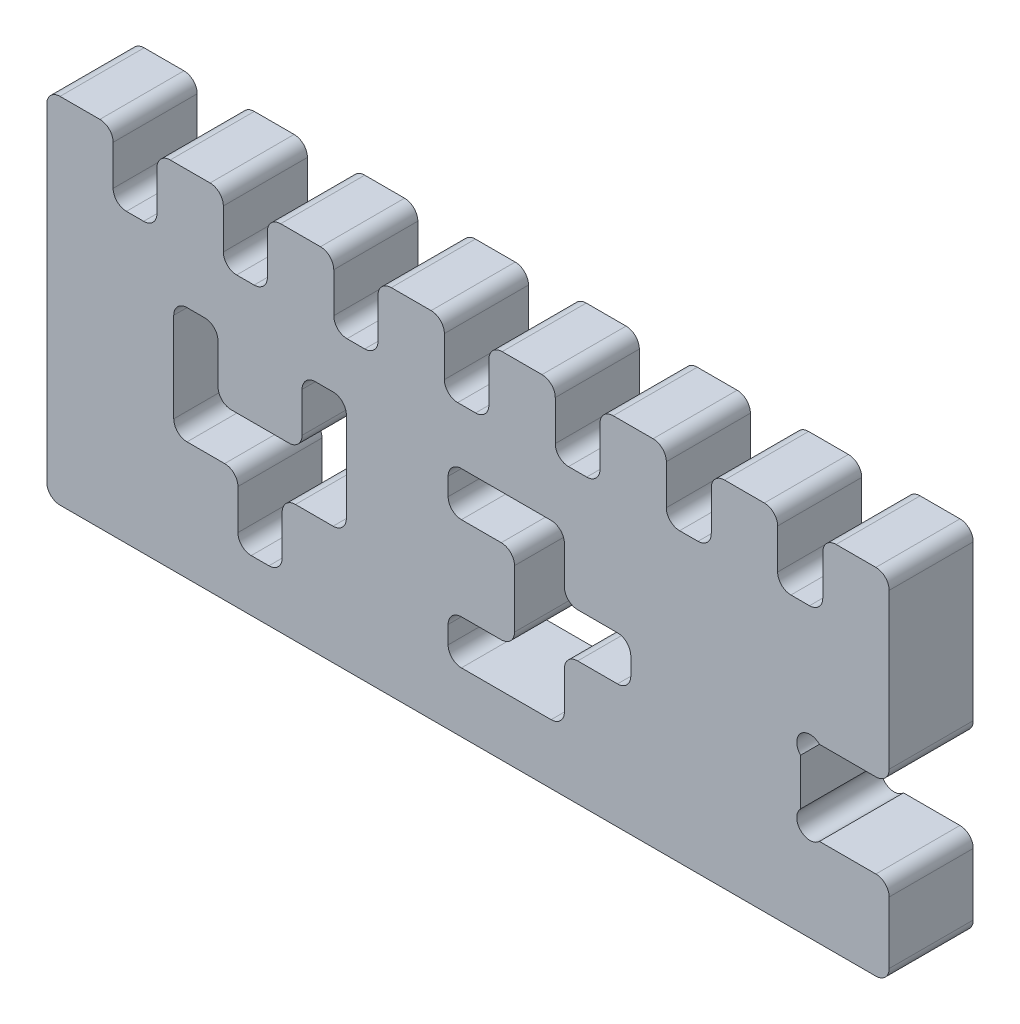
from build123d import *

# Parameters (mm, degrees)
BOSS_EXTRUDE1_DEPTH = 19


with BuildPart() as part:
    # Sketch1 → Boss-Extrude1 (new body)
    with BuildSketch(Plane.XY):
        with BuildLine():
            Line((18, 65), (21.9, 65))
            ThreePointArc((21.9, 65), (24.021320344, 65.878679656), (24.9, 68))
            Line((24.9, 68), (24.9, 77))
            ThreePointArc((24.9, 77), (25.778679656, 79.121320344), (27.9, 80))
            Line((27.9, 80), (36.9, 80))
            ThreePointArc((36.9, 80), (39.021320344, 79.121320344), (39.9, 77))
            Line((39.9, 77), (39.9, 68))
            ThreePointArc((39.9, 68), (40.778679656, 65.878679656), (42.9, 65))
            Line((42.9, 65), (46.85, 65))
            ThreePointArc((46.85, 65), (48.971320344, 65.878679656), (49.85, 68))
            Line((49.85, 68), (49.85, 77))
            ThreePointArc((49.85, 77), (50.728679656, 79.121320344), (52.85, 80))
            Line((52.85, 80), (61.85, 80))
            ThreePointArc((61.85, 80), (63.971320344, 79.121320344), (64.85, 77))
            Line((64.85, 77), (64.85, 68))
            ThreePointArc((64.85, 68), (65.728679656, 65.878679656), (67.85, 65))
            Line((67.85, 65), (71.85, 65))
            ThreePointArc((71.85, 65), (73.971320344, 65.878679656), (74.85, 68))
            Line((74.85, 68), (74.85, 77))
            ThreePointArc((74.85, 77), (75.728679656, 79.121320344), (77.85, 80))
            Line((77.85, 80), (86.85, 80))
            ThreePointArc((86.85, 80), (88.971320344, 79.121320344), (89.85, 77))
            Line((89.85, 77), (89.85, 68))
            ThreePointArc((89.85, 68), (90.728679656, 65.878679656), (92.85, 65))
            Line((92.85, 65), (96.9, 65))
            ThreePointArc((96.9, 65), (99.021320344, 65.878679656), (99.9, 68))
            Line((99.9, 68), (99.9, 77))
            ThreePointArc((99.9, 77), (100.778679656, 79.121320344), (102.9, 80))
            Line((102.9, 80), (111.9, 80))
            ThreePointArc((111.9, 80), (114.021320344, 79.121320344), (114.9, 77))
            Line((114.9, 77), (114.9, 68))
            ThreePointArc((114.9, 68), (115.778679656, 65.878679656), (117.9, 65))
            Line((117.9, 65), (122, 65))
            ThreePointArc((122, 65), (124.121320344, 65.878679656), (125, 68))
            Line((125, 68), (125, 77))
            ThreePointArc((125, 77), (125.878679656, 79.121320344), (128, 80))
            Line((128, 80), (137, 80))
            ThreePointArc((137, 80), (139.121320344, 79.121320344), (140, 77))
            Line((140, 77), (140, 68))
            ThreePointArc((140, 68), (140.878679656, 65.878679656), (143, 65))
            Line((143, 65), (147.15, 65))
            ThreePointArc((147.15, 65), (149.271320344, 65.878679656), (150.15, 68))
            Line((150.15, 68), (150.15, 77))
            ThreePointArc((150.15, 77), (151.028679656, 79.121320344), (153.15, 80))
            Line((153.15, 80), (162.15, 80))
            ThreePointArc((162.15, 80), (164.271320344, 79.121320344), (165.15, 77))
            Line((165.15, 77), (165.15, 68))
            ThreePointArc((165.15, 68), (166.028679656, 65.878679656), (168.15, 65))
            Line((168.15, 65), (172.35, 65))
            ThreePointArc((172.35, 65), (174.471320344, 65.878679656), (175.35, 68))
            Line((175.35, 68), (175.35, 77))
            ThreePointArc((175.35, 77), (176.228679656, 79.121320344), (178.35, 80))
            Line((178.35, 80), (187.35, 80))
            ThreePointArc((187.35, 80), (189.471320344, 79.121320344), (190.35, 77))
            Line((190.35, 77), (190.35, 42))
            ThreePointArc((190.35, 42), (189.471320344, 39.878679656), (187.35, 39))
            Line((187.35, 39), (174.592640687, 39))
            ThreePointArc((174.592640687, 39), (170.35, 39), (170.35, 34.757359313))
            Line((170.35, 34.757359313), (170.35, 24.242640687))
            ThreePointArc((170.35, 24.242640687), (170.35, 20), (174.592640687, 20))
            Line((174.592640687, 20), (187.35, 20))
            ThreePointArc((187.35, 20), (189.471320344, 19.121320344), (190.35, 17))
            Line((190.35, 17), (190.35, 3))
            ThreePointArc((190.35, 3), (189.471320344, 0.878679656), (187.35, 0))
            Line((187.35, 0), (3, 0))
            ThreePointArc((3, 0), (0.878679656, 0.878679656), (0, 3))
            Line((0, 3), (0, 77))
            ThreePointArc((0, 77), (0.878679656, 79.121320344), (3, 80))
            Line((3, 80), (12, 80))
            ThreePointArc((12, 80), (14.121320344, 79.121320344), (15, 77))
            Line((15, 77), (15, 68))
            ThreePointArc((15, 68), (15.878679656, 65.878679656), (18, 65))
        make_face()
        with BuildLine():
            Line((31.694947257, 53.008010391), (35.694947257, 53.008010391))
            ThreePointArc((35.694947257, 53.008010391), (37.8162676, 52.129330734), (38.694947257, 50.008010391))
            Line((38.694947257, 50.008010391), (38.694947257, 41.008010391))
            ThreePointArc((38.694947257, 41.008010391), (39.573626913, 38.886690047), (41.694947257, 38.008010391))
            Line((41.694947257, 38.008010391), (54.694947257, 38.008010391))
            ThreePointArc((54.694947257, 38.008010391), (56.8162676, 38.886690047), (57.694947257, 41.008010391))
            Line((57.694947257, 41.008010391), (57.694947257, 50.008010391))
            ThreePointArc((57.694947257, 50.008010391), (58.573626913, 52.129330734), (60.694947257, 53.008010391))
            Line((60.694947257, 53.008010391), (64.694947257, 53.008010391))
            ThreePointArc((64.694947257, 53.008010391), (66.8162676, 52.129330734), (67.694947257, 50.008010391))
            Line((67.694947257, 50.008010391), (67.694947257, 41.008010391))
            Line((67.694947257, 41.008010391), (67.694947257, 29.736314532))
            ThreePointArc((67.694947257, 29.736314532), (66.8162676, 27.614994188), (64.694947257, 26.736314532))
            Line((64.694947257, 26.736314532), (56.194947257, 26.736314532))
            ThreePointArc((56.194947257, 26.736314532), (54.073626913, 25.857634875), (53.194947257, 23.736314532))
            Line((53.194947257, 23.736314532), (53.194947257, 14.736314532))
            ThreePointArc((53.194947257, 14.736314532), (52.3162676, 12.614994188), (50.194947257, 11.736314532))
            Line((50.194947257, 11.736314532), (46.194947257, 11.736314532))
            ThreePointArc((46.194947257, 11.736314532), (44.073626913, 12.614994188), (43.194947257, 14.736314532))
            Line((43.194947257, 14.736314532), (43.194947257, 23.736314532))
            ThreePointArc((43.194947257, 23.736314532), (42.3162676, 25.857634875), (40.194947257, 26.736314532))
            Line((40.194947257, 26.736314532), (31.694947257, 26.736314532))
            ThreePointArc((31.694947257, 26.736314532), (29.573626913, 27.614994188), (28.694947257, 29.736314532))
            Line((28.694947257, 29.736314532), (28.694947257, 41.008010391))
            Line((28.694947257, 41.008010391), (28.694947257, 50.008010391))
            ThreePointArc((28.694947257, 50.008010391), (29.573626913, 52.129330734), (31.694947257, 53.008010391))
        make_face(mode=Mode.SUBTRACT)
        with BuildLine():
            Line((90.694947257, 16.508010391), (90.694947257, 20.508010391))
            ThreePointArc((90.694947257, 20.508010391), (91.573626913, 22.629330734), (93.694947257, 23.508010391))
            Line((93.694947257, 23.508010391), (102.694947257, 23.508010391))
            ThreePointArc((102.694947257, 23.508010391), (104.8162676, 24.386690047), (105.694947257, 26.508010391))
            Line((105.694947257, 26.508010391), (105.694947257, 39.508010391))
            ThreePointArc((105.694947257, 39.508010391), (104.8162676, 41.629330734), (102.694947257, 42.508010391))
            Line((102.694947257, 42.508010391), (93.694947257, 42.508010391))
            ThreePointArc((93.694947257, 42.508010391), (91.573626913, 43.386690047), (90.694947257, 45.508010391))
            Line((90.694947257, 45.508010391), (90.694947257, 49.508010391))
            ThreePointArc((90.694947257, 49.508010391), (91.573626913, 51.629330734), (93.694947257, 52.508010391))
            Line((93.694947257, 52.508010391), (102.694947257, 52.508010391))
            Line((102.694947257, 52.508010391), (113.966643115, 52.508010391))
            ThreePointArc((113.966643115, 52.508010391), (116.087963459, 51.629330734), (116.966643115, 49.508010391))
            Line((116.966643115, 49.508010391), (116.966643115, 41.008010391))
            ThreePointArc((116.966643115, 41.008010391), (117.845322772, 38.886690047), (119.966643115, 38.008010391))
            Line((119.966643115, 38.008010391), (128.966643115, 38.008010391))
            ThreePointArc((128.966643115, 38.008010391), (131.087963459, 37.129330734), (131.966643115, 35.008010391))
            Line((131.966643115, 35.008010391), (131.966643115, 31.008010391))
            ThreePointArc((131.966643115, 31.008010391), (131.087963459, 28.886690047), (128.966643115, 28.008010391))
            Line((128.966643115, 28.008010391), (119.966643115, 28.008010391))
            ThreePointArc((119.966643115, 28.008010391), (117.845322772, 27.129330734), (116.966643115, 25.008010391))
            Line((116.966643115, 25.008010391), (116.966643115, 16.508010391))
            ThreePointArc((116.966643115, 16.508010391), (116.087963459, 14.386690047), (113.966643115, 13.508010391))
            Line((113.966643115, 13.508010391), (102.694947257, 13.508010391))
            Line((102.694947257, 13.508010391), (93.694947257, 13.508010391))
            ThreePointArc((93.694947257, 13.508010391), (91.573626913, 14.386690047), (90.694947257, 16.508010391))
        make_face(mode=Mode.SUBTRACT)
    extrude(amount=BOSS_EXTRUDE1_DEPTH)


solid = part.part
